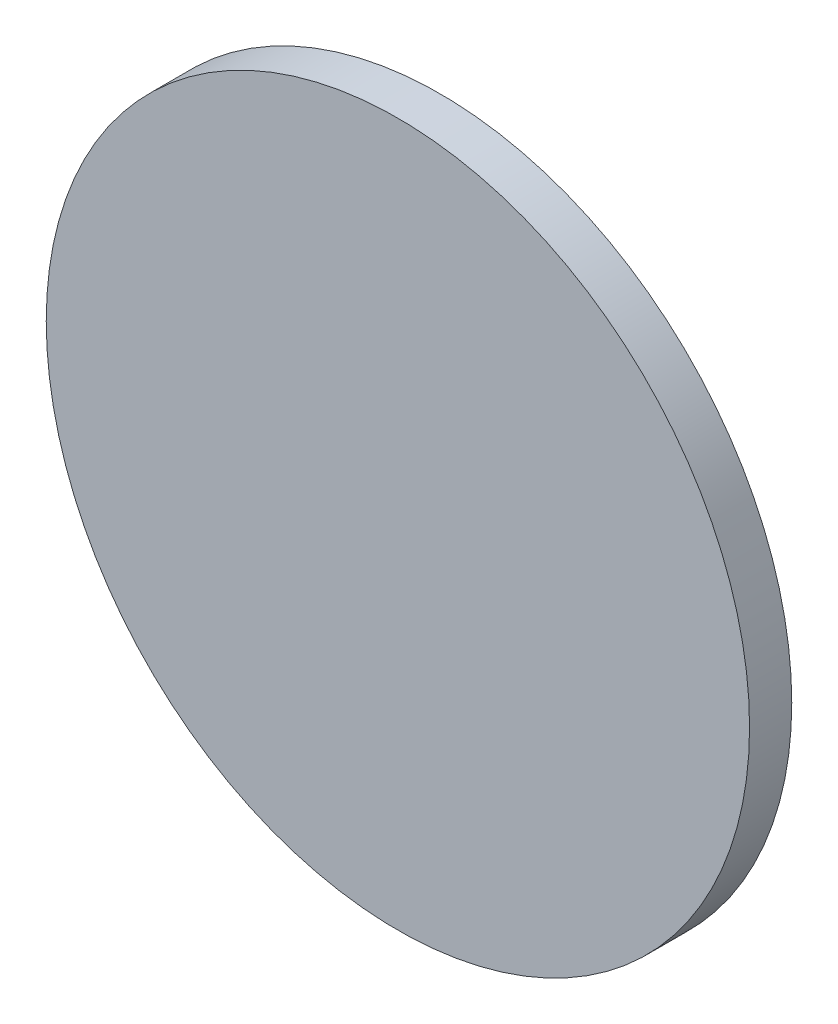
from build123d import *

# Parameters (mm, degrees)
SKETCH2_R           = 25
BOSS_EXTRUDE1_DEPTH = 3


with BuildPart() as part:
    # Sketch2 → Boss-Extrude1 (new body)
    with BuildSketch(Plane.XY):
        Circle(SKETCH2_R)
    extrude(amount=BOSS_EXTRUDE1_DEPTH)


solid = part.part
